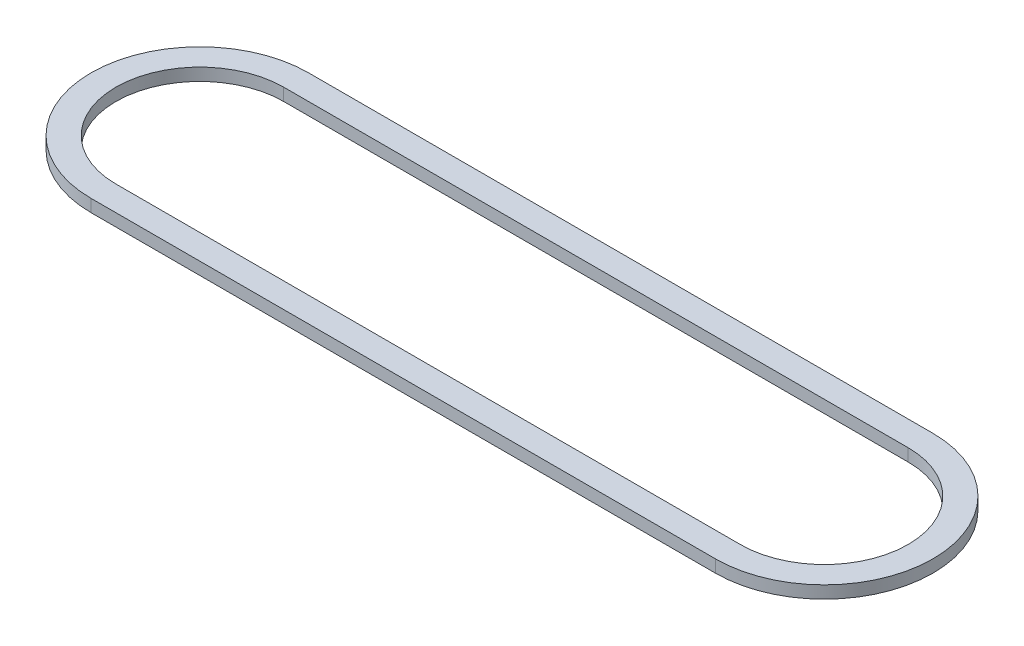
from build123d import *

# Parameters (mm, degrees)
BOSS_EXTRUDE1_DEPTH = 0.508


with BuildPart() as part:
    # Sketch1 → Boss-Extrude1 (new body)
    with BuildSketch(Plane(origin=(0, 0, 0), x_dir=(1, 0, 0), z_dir=(0, 1, 0))):
        with BuildLine():
            Line((-12.7635, 4.445), (12.7635, 4.445))
            ThreePointArc((12.7635, 4.445), (17.2085, 0), (12.7635, -4.445))
            Line((12.7635, -4.445), (-12.7635, -4.445))
            ThreePointArc((-12.7635, -4.445), (-17.2085, 0), (-12.7635, 4.445))
        make_face()
        with BuildLine():
            Line((-12.7635, 3.429), (12.7635, 3.429))
            ThreePointArc((12.7635, 3.429), (16.1925, 0), (12.7635, -3.429))
            Line((12.7635, -3.429), (-12.7635, -3.429))
            ThreePointArc((-12.7635, -3.429), (-16.1925, 0), (-12.7635, 3.429))
        make_face(mode=Mode.SUBTRACT)
    extrude(amount=BOSS_EXTRUDE1_DEPTH)


solid = part.part
